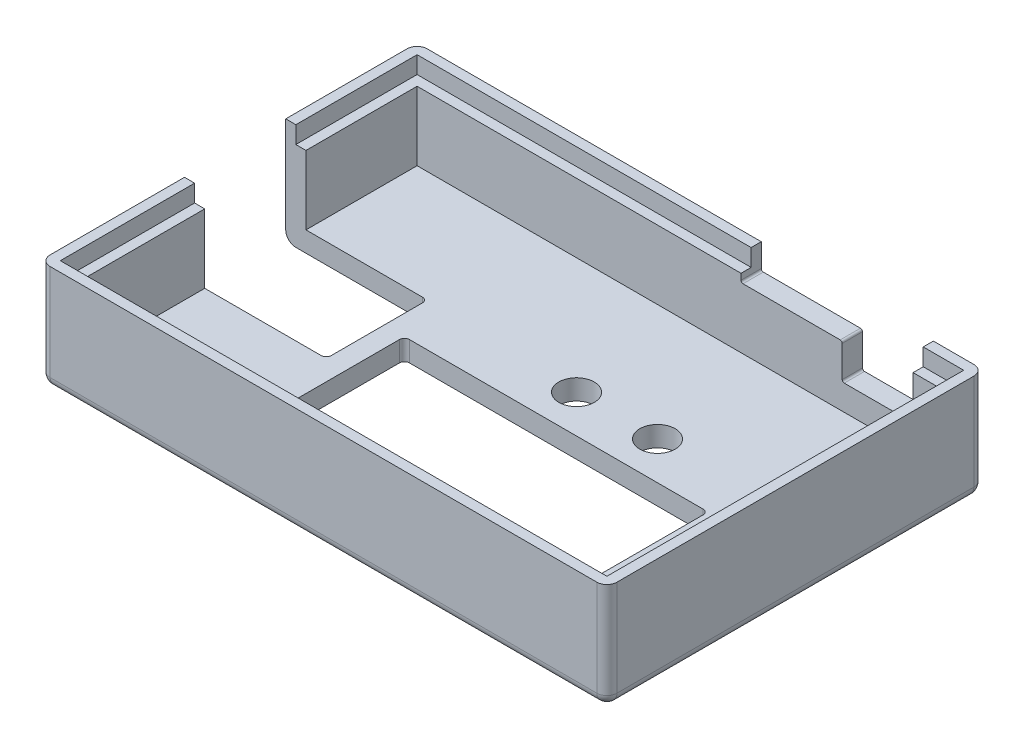
from build123d import *

# Parameters (mm, degrees)
SKETCH1_W           = 56
SKETCH1_H           = 37.25
BOSS_EXTRUDE1_DEPTH = 2
SKETCH2_W           = 56
SKETCH2_H           = 37.25
SKETCH2_W_2         = 52
SKETCH2_H_2         = 33.25
BOSS_EXTRUDE2_DEPTH = 8.5
SKETCH5_W           = 54
SKETCH5_H           = 35.25
SKETCH5_W_2         = 52
SKETCH5_H_2         = 33.25
CUT_EXTRUDE1_DEPTH  = 1
FILLET1_R           = 1
SKETCH7_W           = 30
SKETCH7_H           = 14
CUT_EXTRUDE3_DEPTH  = 10
SKETCH8_R           = 1.75
CUT_EXTRUDE4_DEPTH  = 10
SKETCH9_W           = 7
SKETCH9_H           = 6
CUT_EXTRUDE5_DEPTH  = 3
SKETCH10_W          = 10
SKETCH10_H          = 2.5
CUT_EXTRUDE6_DEPTH  = 3
FILLET2_R           = 0.5
SKETCH11_W          = 14
SKETCH11_H          = 10
CUT_EXTRUDE7_DEPTH  = 11.5
FILLET3_R           = 1
FILLET4_R           = 0.5
FILLET5_R           = 0.2
CUT_EXTRUDE8_DEPTH  = 0.7


with BuildPart() as part:
    # Sketch1 → Boss-Extrude1 (new body)
    with BuildSketch(Plane(origin=(0, 0, 0), x_dir=(1, 0, 0), z_dir=(0, 1, 0))):
        with Locations((28, 18.625)):
            Rectangle(SKETCH1_W, SKETCH1_H)
    extrude(amount=BOSS_EXTRUDE1_DEPTH)

    # Sketch2 → Boss-Extrude2 (add)
    with BuildSketch(Plane(origin=(0, 2, 0), x_dir=(1, 0, 0), z_dir=(0, 1, 0))):
        with Locations((28, 18.625)):
            Rectangle(SKETCH2_W, SKETCH2_H)
        with Locations((28, 18.625)):
            Rectangle(SKETCH2_W_2, SKETCH2_H_2, mode=Mode.SUBTRACT)
    extrude(amount=BOSS_EXTRUDE2_DEPTH)

    # Sketch5 → Cut-Extrude1 (cut)
    with BuildSketch(Plane(origin=(0, 10.5, 0), x_dir=(1, 0, 0), z_dir=(0, 1, 0))):
        with Locations((28, 18.625)):
            Rectangle(SKETCH5_W, SKETCH5_H)
        with Locations((28, 18.625)):
            Rectangle(SKETCH5_W_2, SKETCH5_H_2, mode=Mode.SUBTRACT)
        with Locations((28, 18.625)):
            Rectangle(SKETCH5_W_2, SKETCH5_H_2)
    extrude(amount=-CUT_EXTRUDE1_DEPTH, mode=Mode.SUBTRACT)

    # Fillet1
    fillet1_edges = [part.edges().sort_by_distance(p)[0] for p in [
        (0, 5.25, -37.25),
        (56, 5.25, -37.25),
        (56, 5.25, 0),
        (0, 5.25, 0),
    ]]
    fillet(fillet1_edges, radius=FILLET1_R)

    # Sketch7 → Cut-Extrude3 (cut)
    with BuildSketch(Plane(origin=(0, 2, 0), x_dir=(1, 0, 0), z_dir=(0, 1, 0))):
        with Locations((31, 13)):
            Rectangle(SKETCH7_W, SKETCH7_H)
    extrude(amount=-CUT_EXTRUDE3_DEPTH, mode=Mode.SUBTRACT)

    # Sketch8 → Cut-Extrude4 (cut)
    with BuildSketch(Plane.XZ):
        with Locations((29.24999924, -23.74999914)):
            Circle(SKETCH8_R)
        with Locations((37.25000102, -23.74999914)):
            Circle(SKETCH8_R)
    extrude(amount=-CUT_EXTRUDE4_DEPTH, mode=Mode.SUBTRACT)

    # Sketch9 → Cut-Extrude5 (cut)
    with BuildSketch(Plane(origin=(0, 0, -37.25), x_dir=(-1, 0, 0), z_dir=(0, 0, -1))):
        with Locations((-47.5, 7.5)):
            Rectangle(SKETCH9_W, SKETCH9_H)
    extrude(amount=-CUT_EXTRUDE5_DEPTH, mode=Mode.SUBTRACT)

    # Sketch10 → Cut-Extrude6 (cut)
    with BuildSketch(Plane(origin=(0, 0, -37.25), x_dir=(-1, 0, 0), z_dir=(0, 0, -1))):
        with Locations((-39, 9.25)):
            Rectangle(SKETCH10_W, SKETCH10_H)
    extrude(amount=-CUT_EXTRUDE6_DEPTH, mode=Mode.SUBTRACT)

    # Fillet2
    fillet2_edges = [part.edges().sort_by_distance(p)[0] for p in [
        (16, 1, -6),
        (16, 1, -20),
        (46, 1, -20),
        (46, 1, -6),
    ]]
    fillet(fillet2_edges, radius=FILLET2_R)

    # Sketch11 → Cut-Extrude7 (cut, through all)
    with BuildSketch(Plane.XZ):
        with Locations((7, -19.2710001)):
            Rectangle(SKETCH11_W, SKETCH11_H)
    extrude(amount=-CUT_EXTRUDE7_DEPTH, mode=Mode.SUBTRACT)

    # Fillet3
    fillet3_edges = [part.edges().sort_by_distance(p)[0] for p in [
        (0, 0, -30.26050005),
        (0.292893219, 0, -0.292893219),
        (28, 0, 0),
        (55.707106781, 0, -0.292893219),
        (56, 0, -18.625),
        (55.707106781, 0, -36.957106781),
        (0.292893219, 0, -36.957106781),
        (28, 0, -37.25),
    ]]
    fillet(fillet3_edges, radius=FILLET3_R)

    # Fillet4
    fillet4_edges = [part.edges().sort_by_distance(p)[0] for p in [
        (14, 1, -24.2710001),
        (14, 1, -14.2710001),
    ]]
    fillet(fillet4_edges, radius=FILLET4_R)

    # Fillet5
    fillet5_edges = [part.edges().sort_by_distance(p)[0] for p in [
        (51, 4.5, -36.25),
        (44, 4.5, -36.25),
        (44, 8, -36.25),
        (34, 8, -36.25),
    ]]
    fillet(fillet5_edges, radius=FILLET5_R)

    # Sketch12 → Cut-Extrude8 (cut)
    with BuildSketch(Plane(origin=(0, 9.5, 0), x_dir=(1, 0, 0), z_dir=(0, 1, 0))):
        Polygon((2, 14.2710001), (1, 14.2710001), (1, 1), (55, 1), (55, 36.25), (51, 36.25), (51, 35.25), (54, 35.25), (54, 2), (2, 2), align=None)
        Polygon((1, 24.2710001), (2, 24.2710001), (2, 35.25), (34, 35.25), (34, 36.25), (1, 36.25), align=None)
    extrude(amount=-CUT_EXTRUDE8_DEPTH, mode=Mode.SUBTRACT)


solid = part.part
